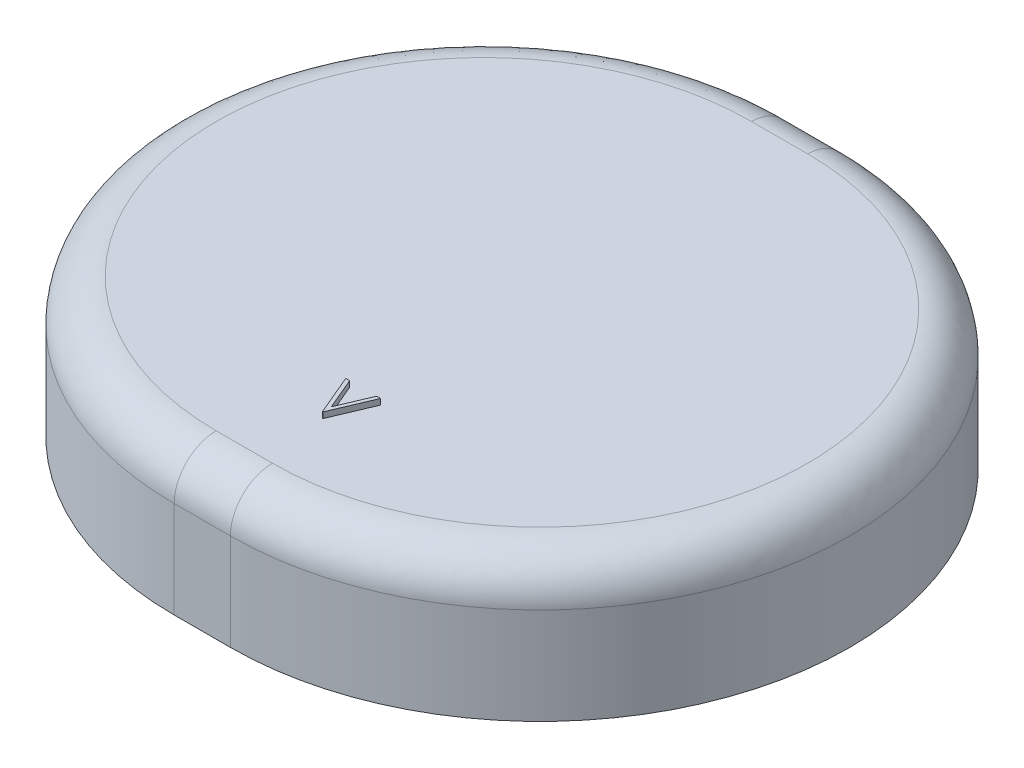
from build123d import *

# Parameters (mm, degrees)
SKETCH3_W                = 12.333298302
SKETCH3_H                = 1
BOSS_EXTRUDE1_DEPTH      = 4
BOSS_EXTRUDE1_DEPTH_BACK = 1
BOSS_EXTRUDE2_DEPTH      = 0.5


with BuildPart() as part:
    # Sweep1: sweep along a path in Sketch1
    with BuildLine(Plane(origin=(0, -28.156757597, 0), x_dir=(1, 0, 0), z_dir=(0, 1, 0))) as sweep1_path:
        Line((1.032552653, 27.955195416), (-3.837557561, 27.953997551))
        ThreePointArc((-3.837557561, 27.953997551), (-29.664515825, 2.114331239), (-3.824849512, -23.712627024))
        Line((-3.824849512, -23.712627024), (1.045260702, -23.71142916))
        ThreePointArc((1.045260702, -23.71142916), (26.872218965, 2.128237152), (1.032552653, 27.955195416))
    # Sketch2 → Sweep1 (sweep)
    with BuildSketch(Plane(origin=(0, 0, 0), x_dir=(0, 0, -1), z_dir=(1, 0, 0))):
        with BuildLine():
            Line((27.954596483, -28.156757597), (27.954596483, -19.795322572))
            ThreePointArc((27.954596483, -19.795322572), (27.181778695, -17.929575385), (25.316031508, -17.156757597))
            Line((25.316031508, -17.156757597), (3.413395706, -17.156757597))
            Line((3.413395706, -17.156757597), (3.413395706, -16.156757597))
            Line((3.413395706, -16.156757597), (25.316031508, -16.156757597))
            ThreePointArc((25.316031508, -16.156757597), (27.888885476, -17.222468604), (28.954596483, -19.795322572))
            Line((28.954596483, -19.795322572), (28.954596483, -28.156757597))
            Line((28.954596483, -28.156757597), (27.954596483, -28.156757597))
        make_face()
    sweep(path=sweep1_path.line)

    # Sketch3 → Boss-Extrude1 (add, two sides)
    with BuildSketch(Plane(origin=(-0.000839567, 0, -3.4133955), x_dir=(0.99999997, 0, -0.000245962), z_dir=(0.000245962, 0, 0.99999997))) as boss_extrude1_sk:
        with Locations((-1.731029698, -16.656757597)):
            Rectangle(SKETCH3_W, SKETCH3_H)
    extrude(amount=BOSS_EXTRUDE1_DEPTH)
    extrude(boss_extrude1_sk.sketch, amount=-BOSS_EXTRUDE1_DEPTH_BACK)

    # Sketch4 → Boss-Extrude2 (add)
    with BuildSketch(Plane(origin=(0, -16.156757597, 0), x_dir=(1, 0, 0), z_dir=(0, 1, 0))):
        Polygon((-1.641529651, -12.033441663), (-1.30499119, -12.033441663), (-0.138324523, -14.791654805), (1.028342144, -12.033441663), (1.364880605, -12.033441663), (-0.115888626, -15.533441663), (-0.160760421, -15.533441663), align=None)
    extrude(amount=BOSS_EXTRUDE2_DEPTH)


solid = part.part
